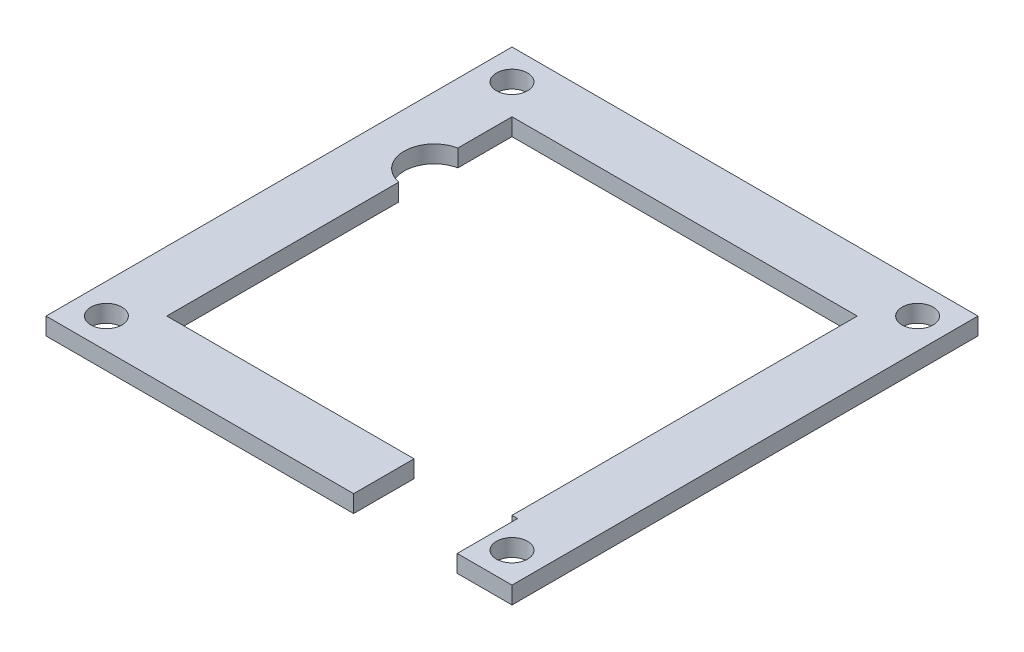
from build123d import *

# Parameters (mm, degrees)
SKETCH_3_R      = 1.8
EXTRUDE_2_DEPTH = 2


with BuildPart() as part:
    # 草图3 → 凸台-拉伸2 (new body)
    with BuildSketch(Plane(origin=(0, 0, 0), x_dir=(1, 0, 0), z_dir=(0, 1, 0))):
        with BuildLine():
            Line((20, 20), (20, -20))
            Line((20, -20), (20.65, -20))
            Line((20.65, -20), (20.65, -27))
            Line((20.65, -27), (27, -27))
            Line((27, -27), (27, 27))
            Line((27, 27), (-27, 27))
            Line((-27, 27), (-27, -27))
            Line((-27, -27), (8.65, -27))
            Line((8.65, -27), (8.65, -20))
            Line((8.65, -20), (-20, -20))
            Line((-20, -20), (-20, 6.87071436))
            ThreePointArc((-20, 6.87071436), (-22.8, 10.3), (-20, 13.72928564))
            Line((-20, 13.72928564), (-20, 20))
            Line((-20, 20), (-16.7, 20))
            Line((-16.7, 20), (-10.4, 20))
            Line((-10.4, 20), (-4.1, 20))
            Line((-4.1, 20), (20, 20))
        make_face()
        with Locations((-23.5, -23.5)):
            Circle(SKETCH_3_R, mode=Mode.SUBTRACT)
        with Locations((23.5, -23.5)):
            Circle(SKETCH_3_R, mode=Mode.SUBTRACT)
        with Locations((-23.5, 23.5)):
            Circle(SKETCH_3_R, mode=Mode.SUBTRACT)
        with Locations((23.5, 23.5)):
            Circle(SKETCH_3_R, mode=Mode.SUBTRACT)
    extrude(amount=EXTRUDE_2_DEPTH)


solid = part.part
